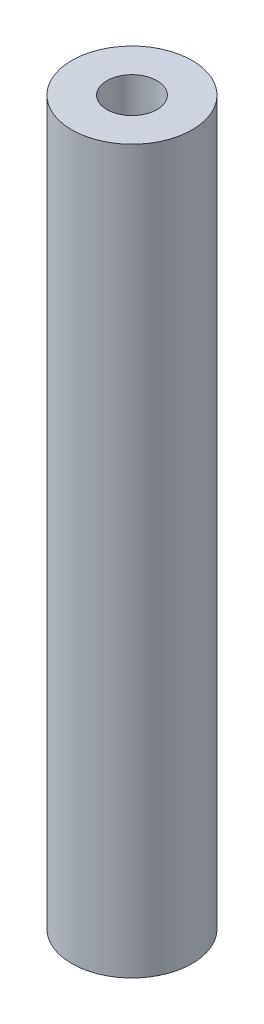
from build123d import *

# Parameters (mm, degrees)
SKETCH1_R                   = 3
BOSS_EXTRUDE1_DEPTH         = 36
TAP_DRILL_FOR_M3_TAP1_D     = 2.5
TAP_DRILL_FOR_M3_TAP1_DEPTH = 10
TAP_DRILL_FOR_M3_TAP1_TIP   = 0.751075774
TAP_DRILL_FOR_M3_TAP2_D     = 2.5
TAP_DRILL_FOR_M3_TAP2_DEPTH = 10
TAP_DRILL_FOR_M3_TAP2_TIP   = 0.751075774


with BuildPart() as part:
    # Sketch1 → Boss-Extrude1 (new body)
    with BuildSketch(Plane(origin=(0, 0, 0), x_dir=(1, 0, 0), z_dir=(0, 1, 0))):
        Circle(SKETCH1_R)
    extrude(amount=BOSS_EXTRUDE1_DEPTH)

    # Tap Drill for M3 Tap1
    with Locations(Plane(origin=(0, 36, 0), x_dir=(1, 0, 0), z_dir=(0, 1, 0))):
        with Locations((0, 0)):
            Hole(TAP_DRILL_FOR_M3_TAP1_D / 2, depth=TAP_DRILL_FOR_M3_TAP1_DEPTH)
            with Locations((0, 0, -(TAP_DRILL_FOR_M3_TAP1_DEPTH + TAP_DRILL_FOR_M3_TAP1_TIP / 2))):  # 118° drill point
                Cone(0, TAP_DRILL_FOR_M3_TAP1_D / 2, TAP_DRILL_FOR_M3_TAP1_TIP, mode=Mode.SUBTRACT)

    # Tap Drill for M3 Tap2
    with Locations(Plane(origin=(0, 0, 0), x_dir=(-1, 0, 0), z_dir=(0, -1, 0))):
        with Locations((0, 0)):
            Hole(TAP_DRILL_FOR_M3_TAP2_D / 2, depth=TAP_DRILL_FOR_M3_TAP2_DEPTH)
            with Locations((0, 0, -(TAP_DRILL_FOR_M3_TAP2_DEPTH + TAP_DRILL_FOR_M3_TAP2_TIP / 2))):  # 118° drill point
                Cone(0, TAP_DRILL_FOR_M3_TAP2_D / 2, TAP_DRILL_FOR_M3_TAP2_TIP, mode=Mode.SUBTRACT)


solid = part.part
